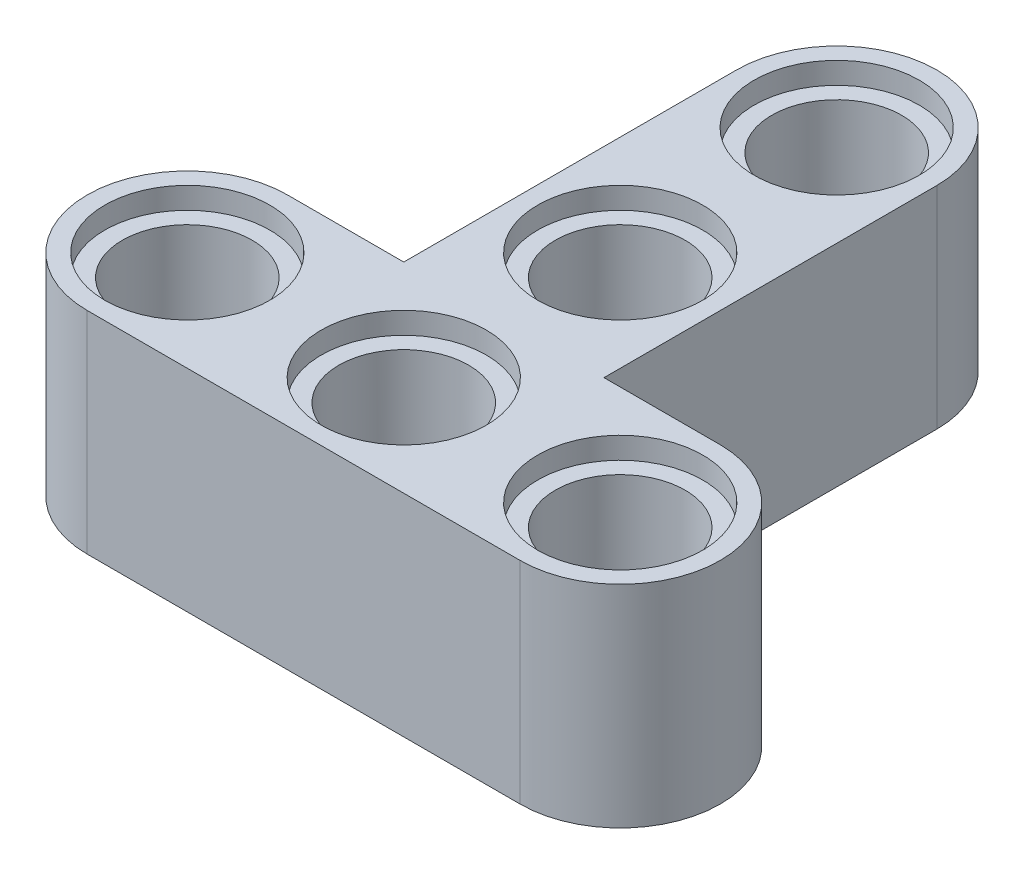
from build123d import *

# Parameters (mm, degrees)
BOSS_EXTRUDE3_DEPTH = 7.8
SKETCH2_R           = 2.4
CUT_EXTRUDE1_DEPTH  = 7.8
SKETCH3_R           = 3.05
CUT_EXTRUDE2_DEPTH  = 0.8
SKETCH4_R           = 3.05
SKETCH4_R_2         = 3.129900969
CUT_EXTRUDE3_DEPTH  = 0.8


with BuildPart() as part:
    # Sketch1 → Boss-Extrude3 (new body)
    with BuildSketch(Plane(origin=(0, 0, 0), x_dir=(1, 0, 0), z_dir=(0, 1, 0))):
        with BuildLine():
            Line((-16, -3.7), (0, -3.7))
            ThreePointArc((0, -3.7), (3.7, 0), (0, 3.7))
            Line((0, 3.7), (-4.3, 3.7))
            Line((-4.3, 3.7), (-4.3, 16))
            ThreePointArc((-4.3, 16), (-8, 19.7), (-11.7, 16))
            Line((-11.7, 16), (-11.7, 3.7))
            Line((-11.7, 3.7), (-16, 3.7))
            ThreePointArc((-16, 3.7), (-19.7, 0), (-16, -3.7))
        make_face()
    extrude(amount=BOSS_EXTRUDE3_DEPTH)

    # Sketch2 → Cut-Extrude1 (cut)
    with BuildSketch(Plane(origin=(0, 7.8, 0), x_dir=(1, 0, 0), z_dir=(0, 1, 0))):
        Circle(SKETCH2_R)
        with Locations((-16, 0)):
            Circle(SKETCH2_R)
        with Locations((-8, 0)):
            Circle(SKETCH2_R)
        with Locations((-8, 8)):
            Circle(SKETCH2_R)
        with Locations((-8, 16)):
            Circle(SKETCH2_R)
    extrude(amount=-CUT_EXTRUDE1_DEPTH, mode=Mode.SUBTRACT)

    # Sketch3 → Cut-Extrude2 (cut)
    with BuildSketch(Plane(origin=(0, 7.8, 0), x_dir=(1, 0, 0), z_dir=(0, 1, 0))):
        Circle(SKETCH3_R)
        with Locations((-16, 0)):
            Circle(SKETCH3_R)
        with Locations((-8, 0)):
            Circle(SKETCH3_R)
        with Locations((-8, 8)):
            Circle(SKETCH3_R)
        with Locations((-8, 16)):
            Circle(SKETCH3_R)
    extrude(amount=-CUT_EXTRUDE2_DEPTH, mode=Mode.SUBTRACT)

    # Sketch4 → Cut-Extrude3 (cut)
    with BuildSketch(Plane.XZ):
        Circle(SKETCH4_R)
        with Locations((-16, 0)):
            Circle(SKETCH4_R)
        with Locations((-8, 0)):
            Circle(SKETCH4_R)
        with Locations((-8, -16)):
            Circle(SKETCH4_R_2)
        with Locations((-8, -8)):
            Circle(SKETCH4_R)
    extrude(amount=-CUT_EXTRUDE3_DEPTH, mode=Mode.SUBTRACT)


solid = part.part
